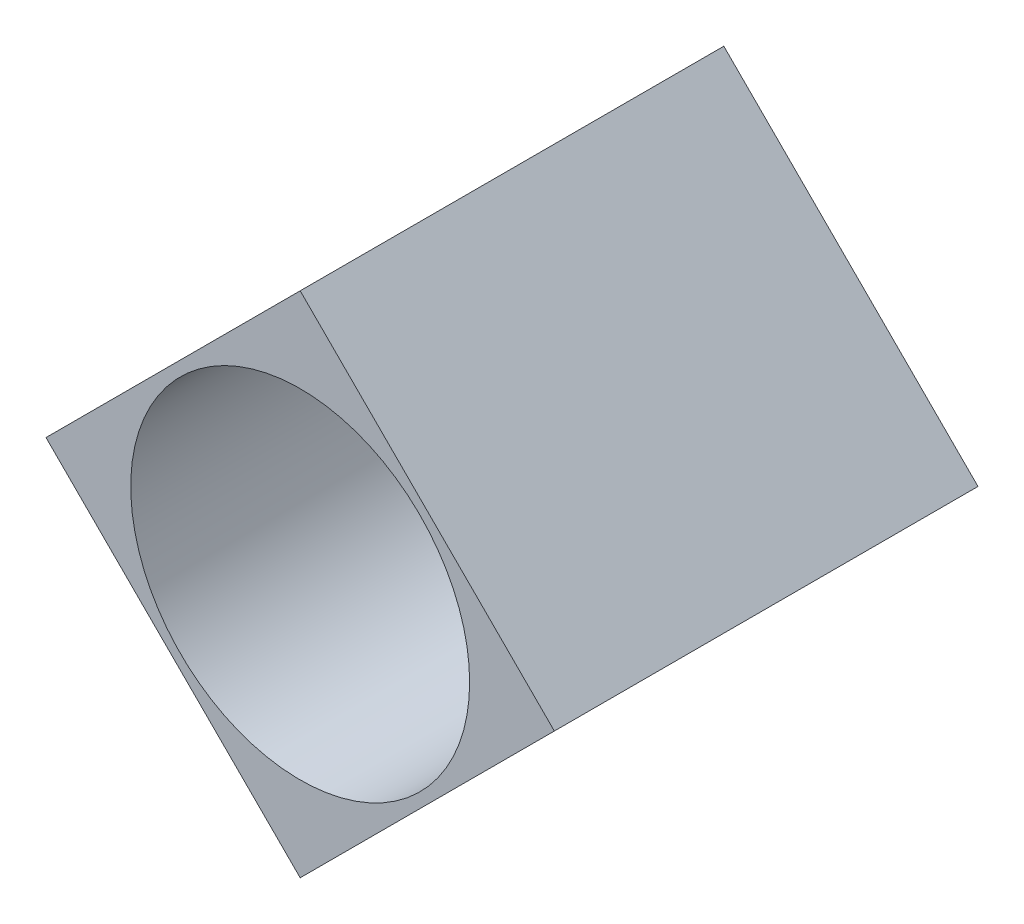
from build123d import *

# Parameters (mm, degrees)
CROQUIS1_R              = 2
SALIENTE_EXTRUIR1_DEPTH = 5


with BuildPart() as part:
    # Croquis1 → Saliente-Extruir1 (new body)
    with BuildSketch(Plane.XY):
        Polygon((0, 3), (3, 0), (0, -3), (-3, 0), align=None)
        Circle(CROQUIS1_R, mode=Mode.SUBTRACT)
    extrude(amount=SALIENTE_EXTRUIR1_DEPTH)


solid = part.part
